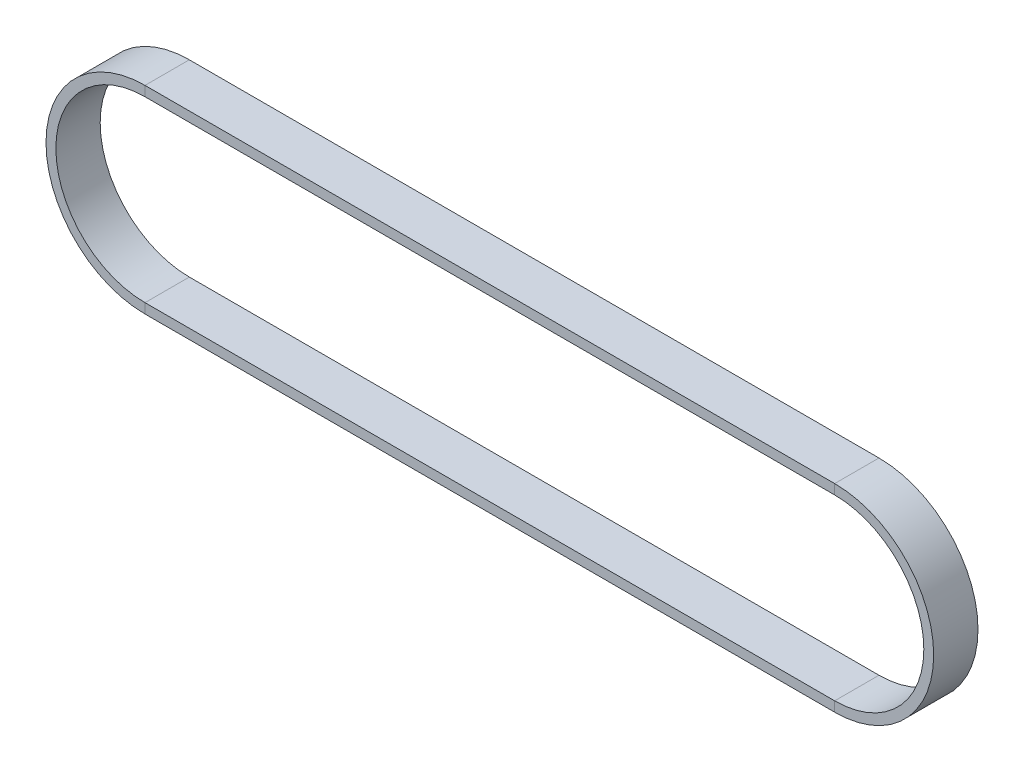
from build123d import *

# Parameters (mm, degrees)
SKETCH2_W = 9
SKETCH2_H = 2


with BuildPart() as part:
    # Sweep1: sweep along a path in Sketch1
    with BuildLine(Plane.XY) as sweep1_path:
        Line((0, 19.1008), (140.02512, 19.1008))
        ThreePointArc((140.02512, 19.1008), (159.12592, 0), (140.02512, -19.1008))
        Line((140.02512, -19.1008), (0, -19.1008))
        ThreePointArc((0, -19.1008), (-19.1008, 0), (0, 19.1008))
    # Sketch2 → Sweep1 (sweep)
    with BuildSketch(Plane(origin=(0, 0, 0), x_dir=(0, 0, -1), z_dir=(1, 0, 0))):
        with Locations((0, 19.1008)):
            Rectangle(SKETCH2_W, SKETCH2_H)
    sweep(path=sweep1_path.line)


solid = part.part
